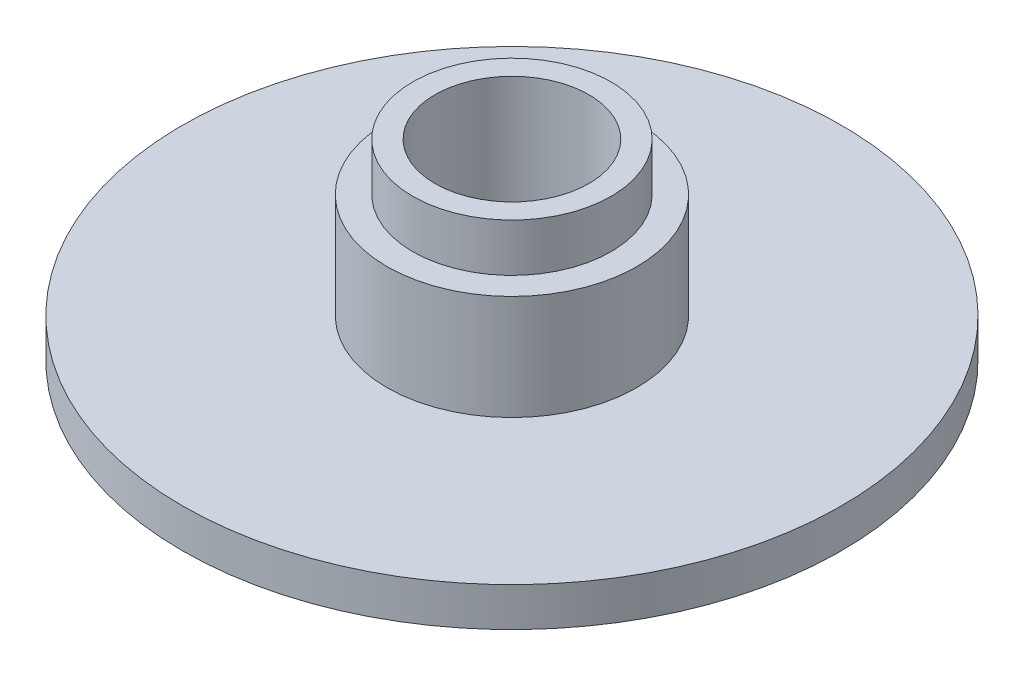
from build123d import *

# Parameters (mm, degrees)
BASE_R              = 27.5
BASE_R_2            = 10.425
BASE_R_3            = 6.425
BASE_R_4            = 8.275
BOSS_EXTRUDE1_DEPTH = 3.25
BASE_4_R            = 8.275
BASE_4_R_2          = 6.425
BOSS_EXTRUDE2_DEPTH = 16
BASE_5_R            = 10.425
BASE_5_R_2          = 8.275
BOSS_EXTRUDE3_DEPTH = 12


with BuildPart() as part:
    # Base → Boss-Extrude1 (new body)
    with BuildSketch(Plane(origin=(0, 0, 0), x_dir=(1, 0, 0), z_dir=(0, 1, 0))):
        Circle(BASE_R)
        Circle(BASE_R_2, mode=Mode.SUBTRACT)
        Circle(BASE_R_2)
        Circle(BASE_R_3, mode=Mode.SUBTRACT)
        Circle(BASE_R_4)
        Circle(BASE_R_3, mode=Mode.SUBTRACT)
    extrude(amount=BOSS_EXTRUDE1_DEPTH)

    # Base_4 → Boss-Extrude2 (add)
    with BuildSketch(Plane(origin=(0, 0, 0), x_dir=(1, 0, 0), z_dir=(0, 1, 0))):
        Circle(BASE_4_R)
        Circle(BASE_4_R_2, mode=Mode.SUBTRACT)
    extrude(amount=BOSS_EXTRUDE2_DEPTH)

    # Base_5 → Boss-Extrude3 (add)
    with BuildSketch(Plane(origin=(0, 0, 0), x_dir=(1, 0, 0), z_dir=(0, 1, 0))):
        Circle(BASE_5_R)
        Circle(BASE_5_R_2, mode=Mode.SUBTRACT)
    extrude(amount=BOSS_EXTRUDE3_DEPTH)


solid = part.part
